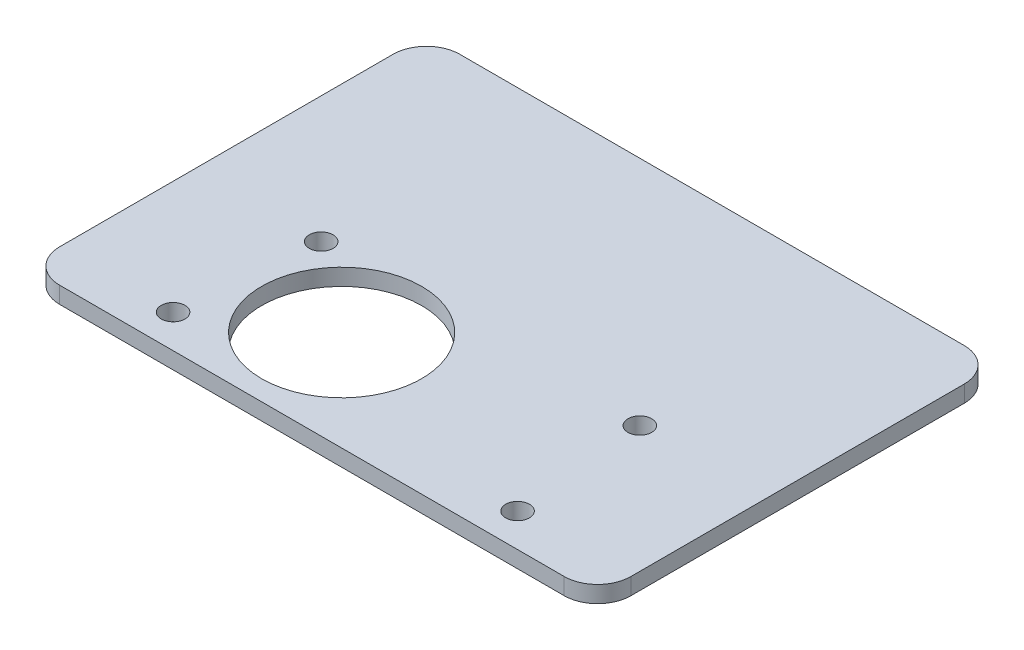
from build123d import *

# Parameters (mm, degrees)
SKETCH_1_R      = 7.62
SKETCH_1_R_2    = 1.1303
EXTRUDE_1_DEPTH = 1.5875


with BuildPart() as part:
    # 草图1 → 凸台-拉伸1 (new body)
    with BuildSketch(Plane.XZ.offset(4.7625)):
        with BuildLine():
            Line((33.9, -25.4), (33.9, 6.35))
            ThreePointArc((33.9, 6.35), (32.97006403, 8.59506403), (30.725, 9.525))
            Line((30.725, 9.525), (-17.325, 9.525))
            ThreePointArc((-17.325, 9.525), (-19.57006403, 8.59506403), (-20.5, 6.35))
            Line((-20.5, 6.35), (-20.5, -25.4))
            ThreePointArc((-20.5, -25.4), (-19.57006403, -27.64506403), (-17.325, -28.575))
            Line((-17.325, -28.575), (30.725, -28.575))
            ThreePointArc((30.725, -28.575), (32.97006403, -27.64506403), (33.9, -25.4))
        make_face()
        Circle(SKETCH_1_R, mode=Mode.SUBTRACT)
        with Locations((-9.705, 6.35)):
            Circle(SKETCH_1_R_2, mode=Mode.SUBTRACT)
        with Locations((23.105, 6.35)):
            Circle(SKETCH_1_R_2, mode=Mode.SUBTRACT)
        with Locations((21.875, -6.525)):
            Circle(SKETCH_1_R_2, mode=Mode.SUBTRACT)
        with Locations((-8.475, -6.525)):
            Circle(SKETCH_1_R_2, mode=Mode.SUBTRACT)
    extrude(amount=-EXTRUDE_1_DEPTH)


solid = part.part
